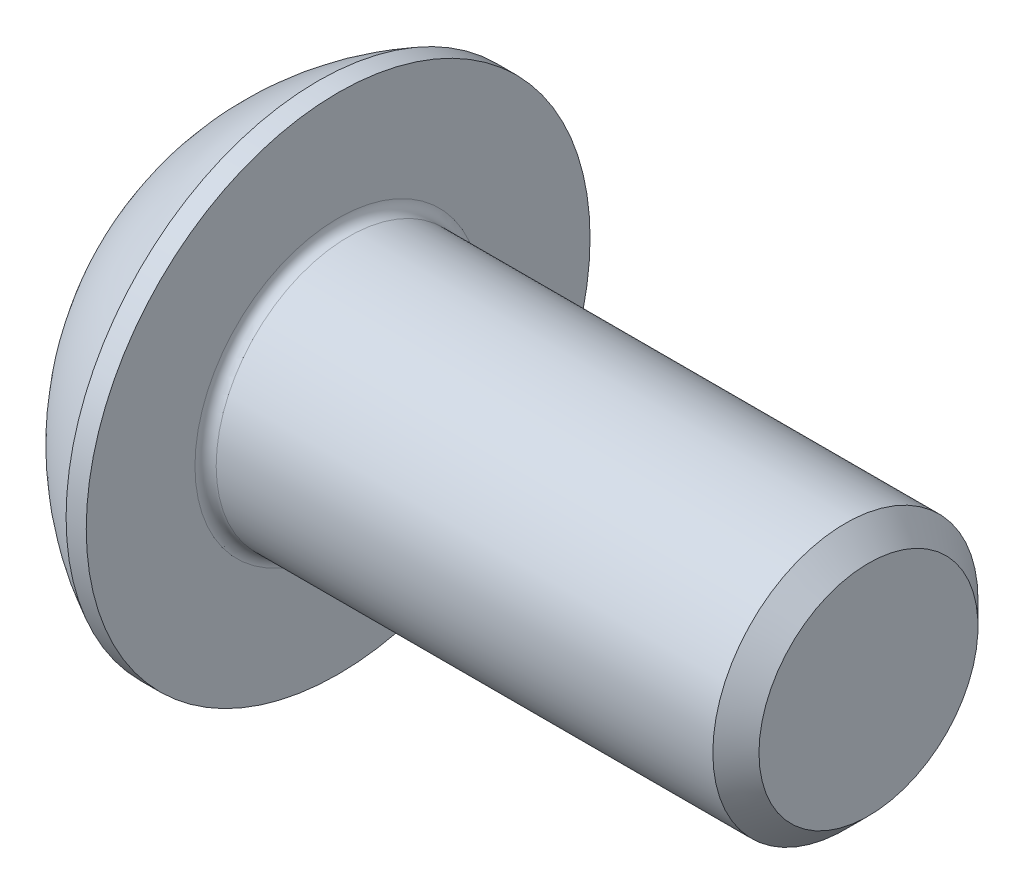
from build123d import *

# Parameters (mm, degrees)
FILLET1_R   = 0.2
HEX_2_DEPTH = 1.5


with BuildPart() as part:
    # BodySke → BaseBody (revolve)
    with BuildSketch(Plane.XY):
        with BuildLine():
            Line((12.75, 0), (12.75, 2.065))
            Line((12.75, 2.065), (12.315, 2.5))
            Line((12.315, 2.5), (2.75, 2.5))
            Line((2.75, 2.5), (2.75, 4.75))
            Line((2.75, 4.75), (2.37, 4.75))
            ThreePointArc((2.37, 4.75), (0.992680215, 3.754414901), (0, 2.375))
            Line((0, 2.375), (0, 0))
            Line((0, 0), (12.75, 0))
        make_face()
    revolve(axis=Axis((0, 0, 0), (1, 0, 0)))

    # Fillet1
    fillet1_edges = [part.edges().sort_by_distance(p)[0] for p in [
        (2.75, -2.5, 0),
    ]]
    fillet(fillet1_edges, radius=FILLET1_R)

    # Sketch2 → PreBroach (revolve, cut)
    with BuildSketch(Plane.XY):
        Polygon((0, 1.25), (1.3, 1.25), (2.021687836, 0), (0, 0), align=None)
    revolve(axis=Axis((0, 0, 0), (1, 0, 0)), mode=Mode.SUBTRACT)

    # Sketch3 → Hex 2 (cut)
    with BuildSketch(Plane(origin=(0, 0, 0), x_dir=(0, 0, -1), z_dir=(1, 0, 0))):
        Polygon((-1.5, -0.866025404), (-1.5, 0.866025404), (0, 1.732050808), (1.5, 0.866025404), (1.5, -0.866025404), (0, -1.732050808), align=None)
    extrude(amount=HEX_2_DEPTH, mode=Mode.SUBTRACT)


solid = part.part
